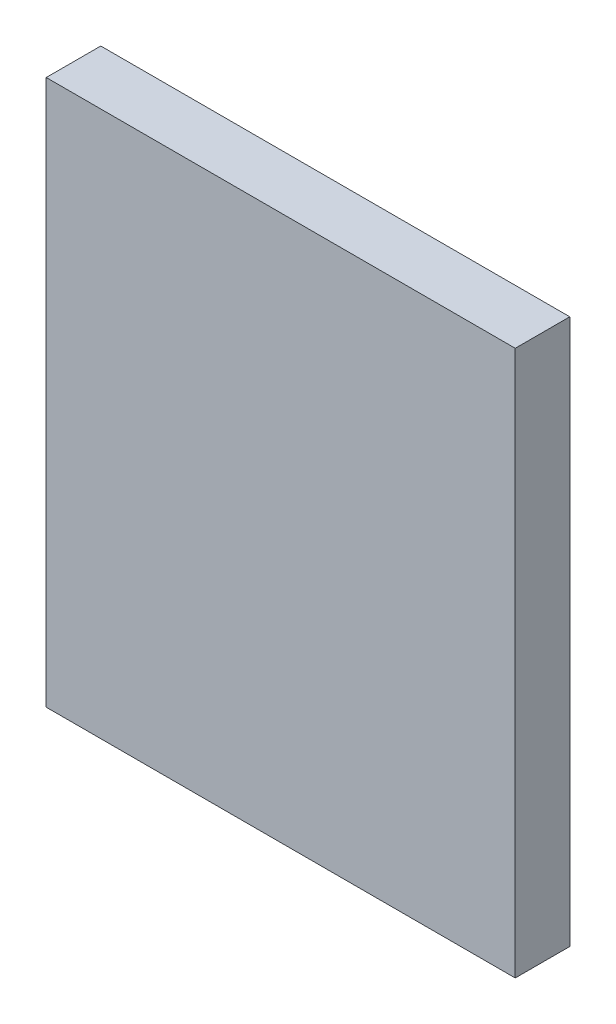
from build123d import *

# Parameters (mm, degrees)
SKETCH1_W           = 215
SKETCH1_H           = 250
BOSS_EXTRUDE1_DEPTH = 25


with BuildPart() as part:
    # Sketch1 → Boss-Extrude1 (new body)
    with BuildSketch(Plane.XY):
        with Locations((107.5, 125)):
            Rectangle(SKETCH1_W, SKETCH1_H)
    extrude(amount=BOSS_EXTRUDE1_DEPTH)


solid = part.part
